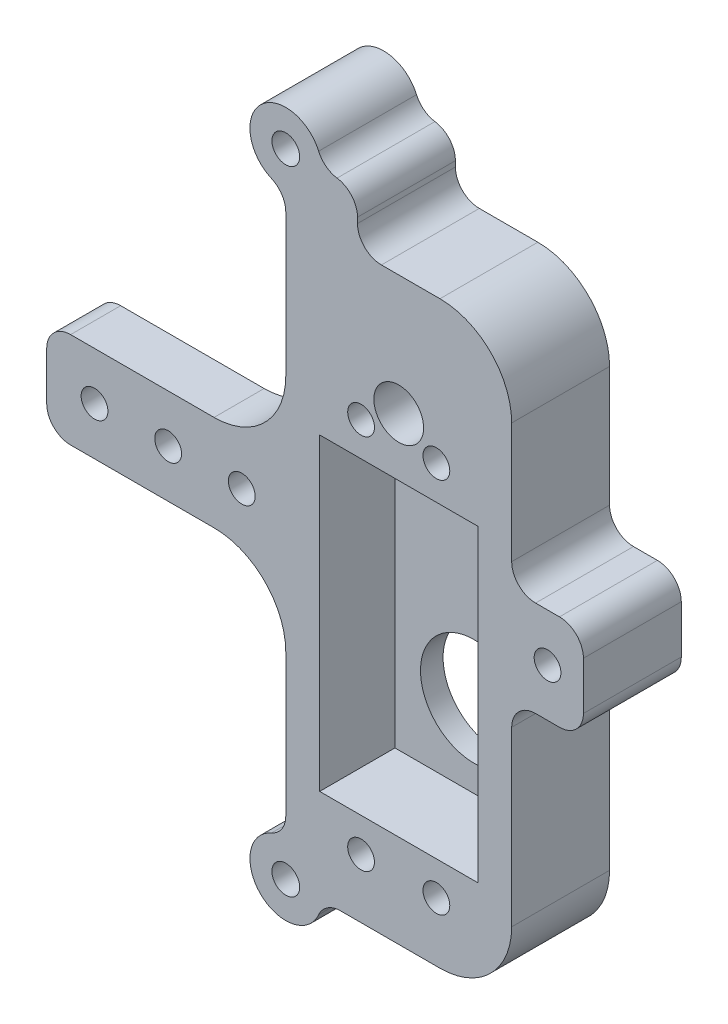
from build123d import *

# Parameters (mm, degrees)
SKETCH1_W           = 31.75
SKETCH1_H           = 12.7
SKETCH1_W_2         = 30
SKETCH1_H_2         = 7
BOSS_EXTRUDE1_DEPTH = 13
SKETCH4_R           = 1.778
CUT_EXTRUDE3_DEPTH  = 14
SKETCH5_W           = 21
SKETCH5_H           = 41
CUT_EXTRUDE4_DEPTH  = 10
SKETCH6_R           = 7.112
CUT_EXTRUDE5_DEPTH  = 4
SKETCH7_W           = 31.75
SKETCH7_H           = 12.7
CUT_EXTRUDE6_DEPTH  = 6.35
SKETCH8_R           = 1.778
CUT_EXTRUDE7_DEPTH  = 7.65
SKETCH10_R          = 1.905
CUT_EXTRUDE8_DEPTH  = 14
SKETCH11_R          = 3.302
CUT_EXTRUDE9_DEPTH  = 9.525
SKETCH13_W          = 9.525
SKETCH13_H          = 12.7
SKETCH13_R          = 1.778
BOSS_EXTRUDE2_DEPTH = 13
BOSS_EXTRUDE3_DEPTH = 13
SKETCH18_R          = 1.8415
CUT_EXTRUDE10_DEPTH = 14
FILLET1_R           = 9.525
FILLET2_R           = 3.175
FILLET3_R           = 3.175


with BuildPart() as part:
    # Sketch1 → Boss-Extrude1 (new body)
    with BuildSketch(Plane.XY):
        Polygon((31.75, 12.7), (31.75, 0), (31.75, -28.65), (61.75, -28.65), (61.75, 0), (61.75, 12.7), (61.75, 41.35), (31.75, 41.35), align=None)
        with Locations((15.875, 6.35)):
            Rectangle(SKETCH1_W, SKETCH1_H)
        with Locations((46.75, -32.15)):
            Rectangle(SKETCH1_W_2, SKETCH1_H_2)
    extrude(amount=BOSS_EXTRUDE1_DEPTH)

    # Sketch4 → Cut-Extrude3 (cut, through all)
    with BuildSketch(Plane.XY.offset(13)):
        with Locations((41.75, 22.199999832)):
            Circle(SKETCH4_R)
        with Locations((51.75, 22.199999832)):
            Circle(SKETCH4_R)
        with Locations((41.75, -27.800000168)):
            Circle(SKETCH4_R)
        with Locations((51.75, -27.800000168)):
            Circle(SKETCH4_R)
    extrude(amount=-CUT_EXTRUDE3_DEPTH, mode=Mode.SUBTRACT)

    # Sketch5 → Cut-Extrude4 (cut)
    with BuildSketch(Plane.XY.offset(13)):
        with Locations((46.75, -2.800000024)):
            Rectangle(SKETCH5_W, SKETCH5_H)
    extrude(amount=-CUT_EXTRUDE4_DEPTH, mode=Mode.SUBTRACT)

    # Sketch6 → Cut-Extrude5 (cut, through all)
    with BuildSketch(Plane.XY.offset(3)):
        with Locations((46.75, -12.700000168)):
            Circle(SKETCH6_R)
    extrude(amount=-CUT_EXTRUDE5_DEPTH, mode=Mode.SUBTRACT)

    # Sketch7 → Cut-Extrude6 (cut)
    with BuildSketch(Plane(origin=(0, 0, 0), x_dir=(-1, 0, 0), z_dir=(0, 0, -1))):
        with Locations((-15.875, 6.35)):
            Rectangle(SKETCH7_W, SKETCH7_H)
    extrude(amount=-CUT_EXTRUDE6_DEPTH, mode=Mode.SUBTRACT)

    # Sketch8 → Cut-Extrude7 (cut, through all)
    with BuildSketch(Plane(origin=(0, 0, 6.35), x_dir=(-1, 0, 0), z_dir=(0, 0, -1))):
        with Locations((-6.35, 6.35)):
            Circle(SKETCH8_R)
        with Locations((-25.908, 6.35)):
            Circle(SKETCH8_R)
        with Locations((-16.129, 6.35)):
            Circle(SKETCH8_R)
    extrude(amount=-CUT_EXTRUDE7_DEPTH, mode=Mode.SUBTRACT)

    # Sketch10 → Cut-Extrude8 (cut, through all)
    with BuildSketch(Plane(origin=(0, 0, 0), x_dir=(-1, 0, 0), z_dir=(0, 0, -1))):
        with Locations((-46.75, 25.4)):
            Circle(SKETCH10_R)
    extrude(amount=-CUT_EXTRUDE8_DEPTH, mode=Mode.SUBTRACT)

    # Sketch11 → Cut-Extrude9 (cut)
    with BuildSketch(Plane.XY.offset(13)):
        with Locations((46.75, 25.4)):
            Circle(SKETCH11_R)
    extrude(amount=-CUT_EXTRUDE9_DEPTH, mode=Mode.SUBTRACT)

    # Sketch13 → Boss-Extrude2 (add)
    with BuildSketch(Plane.XY.offset(13)):
        with Locations((66.5125, 6.35)):
            Rectangle(SKETCH13_W, SKETCH13_H)
        with Locations((66.5125, 6.35)):
            Circle(SKETCH13_R, mode=Mode.SUBTRACT)
    extrude(amount=-BOSS_EXTRUDE2_DEPTH)

    # Sketch17 → Boss-Extrude3 (add)
    with BuildSketch(Plane.XY.offset(13)):
        with BuildLine():
            ThreePointArc((36.5125, 48.359214074), (28.382403955, 51.726810119), (31.75, 43.596714074))
            Line((31.75, 43.596714074), (31.75, 48.359214074))
            Line((31.75, 48.359214074), (36.5125, 48.359214074))
        make_face()
        with BuildLine():
            Line((31.75, 48.359214074), (31.75, 43.596714074))
            ThreePointArc((31.75, 43.596714074), (35.117596045, 44.991618029), (36.5125, 48.359214074))
            Line((36.5125, 48.359214074), (31.75, 48.359214074))
        make_face()
        with BuildLine():
            Line((31.75, 43.596714074), (31.75, 41.35))
            Line((31.75, 41.35), (41.275, 41.35))
            Line((41.275, 41.35), (41.275, 48.359214074))
            Line((41.275, 48.359214074), (36.5125, 48.359214074))
            ThreePointArc((36.5125, 48.359214074), (35.117596045, 44.991618029), (31.75, 43.596714074))
        make_face()
        with BuildLine():
            Line((31.75, -35.65), (36.5125, -35.65))
            ThreePointArc((36.5125, -35.65), (35.117596045, -32.282403955), (31.75, -30.8875))
            Line((31.75, -30.8875), (31.75, -35.65))
        make_face()
        with BuildLine():
            ThreePointArc((31.75, -30.8875), (28.382403955, -39.017596045), (36.5125, -35.65))
            Line((36.5125, -35.65), (31.75, -35.65))
            Line((31.75, -35.65), (31.75, -30.8875))
        make_face()
    extrude(amount=-BOSS_EXTRUDE3_DEPTH)

    # Sketch18 → Cut-Extrude10 (cut, through all)
    with BuildSketch(Plane.XY.offset(13)):
        with Locations((31.75, -35.65)):
            Circle(SKETCH18_R)
        with Locations((31.75, 48.359214074)):
            Circle(SKETCH18_R)
    extrude(amount=-CUT_EXTRUDE10_DEPTH, mode=Mode.SUBTRACT)

    # Fillet1
    fillet1_edges = [part.edges().sort_by_distance(p)[0] for p in [
        (31.75, 0, 9.675),
        (31.75, 12.7, 9.675),
        (61.75, 41.35, 6.5),
        (61.75, -35.65, 6.5),
    ]]
    fillet(fillet1_edges, radius=FILLET1_R)

    # Fillet2
    fillet2_edges = [part.edges().sort_by_distance(p)[0] for p in [
        (71.275, 0, 6.5),
        (71.275, 12.7, 6.5),
        (61.75, 12.7, 6.5),
        (61.75, 0, 6.5),
        (31.75, -30.8875, 6.5),
        (36.5125, -35.65, 6.5),
        (31.75, 43.596714074, 6.5),
        (41.275, 41.35, 6.5),
        (36.5125, 48.359214074, 6.5),
    ]]
    fillet(fillet2_edges, radius=FILLET2_R)

    # Fillet3
    fillet3_edges = [part.edges().sort_by_distance(p)[0] for p in [
        (41.275, 48.359214074, 6.5),
        (0, 12.7, 9.675),
        (0, 0, 9.675),
    ]]
    fillet(fillet3_edges, radius=FILLET3_R)


solid = part.part
